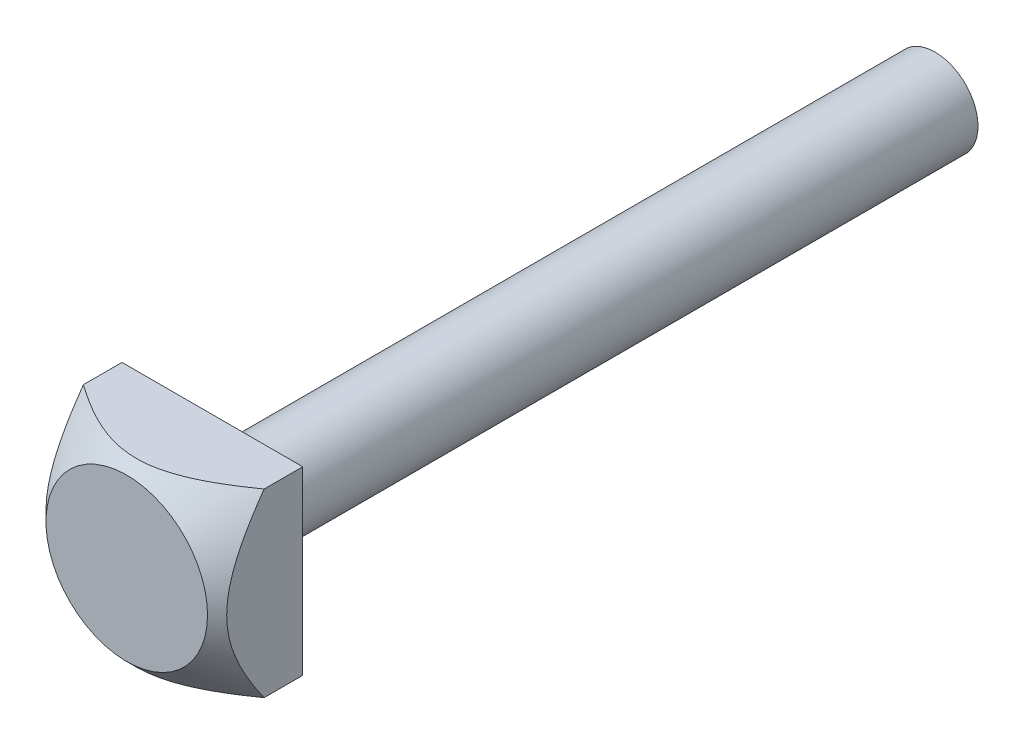
from build123d import *

# Parameters (mm, degrees)
SKETCH1_W           = 19
SKETCH1_H           = 19
BOSS_EXTRUDE1_DEPTH = 9
SKETCH2_OUTSIDE_W   = 44.668
SKETCH2_OUTSIDE_H   = 44.668
SKETCH2_OUTSIDE_R   = 8.492914758
CUT_EXTRUDE1_DEPTH  = 9
CUT_EXTRUDE1_DRAFT  = -45
SKETCH3_R           = 4.5
BOSS_EXTRUDE2_DEPTH = 76


with BuildPart() as part:
    # Sketch1 → Boss-Extrude1 (new body)
    with BuildSketch(Plane.XY):
        Rectangle(SKETCH1_W, SKETCH1_H)
    extrude(amount=BOSS_EXTRUDE1_DEPTH)


with BuildPart() as cut_extrude1_tool:
    # Sketch2 outside → Cut-Extrude1 (with draft: the straight prism first)
    with BuildSketch(Plane.XY.offset(9)):
        Rectangle(SKETCH2_OUTSIDE_W, SKETCH2_OUTSIDE_H)
        Circle(SKETCH2_OUTSIDE_R, mode=Mode.SUBTRACT)
    extrude(amount=-CUT_EXTRUDE1_DEPTH)
    # Cut-Extrude1: the draft: its side faces are tilted about the plane it starts from
    cut_extrude1_sides = [cut_extrude1_tool.faces().sort_by_distance(p)[0] for p in [
        (0, -22.334, 4.5),
        (22.334, 0, 4.5),
        (0, 22.334, 4.5),
        (-22.334, 0, 4.5),
        (-8.492914758, 0, 4.5),
    ]]
    draft(cut_extrude1_sides, Plane.XY.offset(9), CUT_EXTRUDE1_DRAFT)


with BuildPart() as part_1:
    add(part.part)

    # Cut-Extrude1: cut by cut_extrude1_tool
    add(cut_extrude1_tool.part, mode=Mode.SUBTRACT)

    # Sketch3 → Boss-Extrude2 (add)
    with BuildSketch(Plane(origin=(0, 0, 0), x_dir=(-1, 0, 0), z_dir=(0, 0, -1))):
        with Locations(Location((0, 0, 0), (0, 0, 180))):  # turned: the seam where the file's is
            Circle(SKETCH3_R)
    extrude(amount=BOSS_EXTRUDE2_DEPTH)


solid = part_1.part
